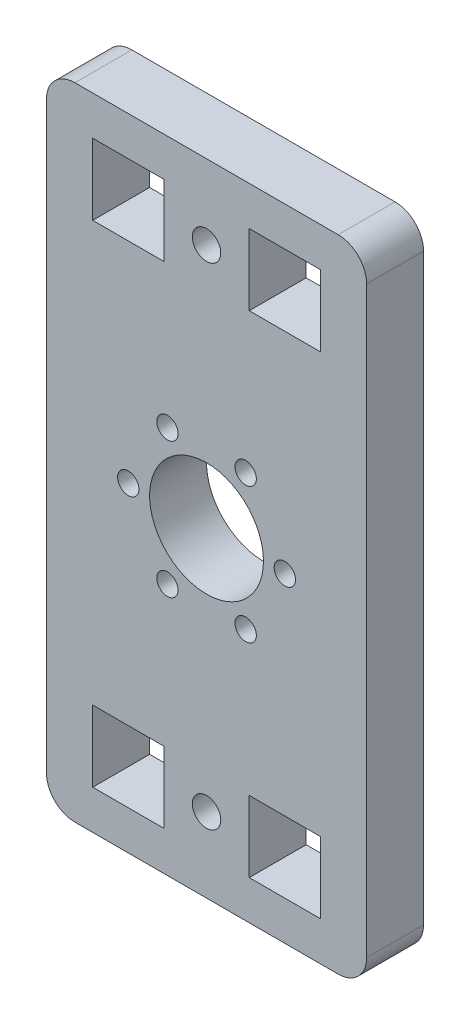
from build123d import *

# Parameters (mm, degrees)
SKETCH1_R           = 8
SKETCH1_R_2         = 1.5
SKETCH1_R_3         = 2
SKETCH1_W           = 10
SKETCH1_H           = 10
BOSS_EXTRUDE2_DEPTH = 8


with BuildPart() as part:
    # Sketch1 → Boss-Extrude2 (new body)
    with BuildSketch(Plane.XY):
        with BuildLine():
            Line((18.5, -45), (-18.5, -45))
            ThreePointArc((-18.5, -45), (-21.328427125, -43.828427125), (-22.5, -41))
            Line((-22.5, -41), (-22.5, 41))
            ThreePointArc((-22.5, 41), (-21.328427125, 43.828427125), (-18.5, 45))
            Line((-18.5, 45), (18.5, 45))
            ThreePointArc((18.5, 45), (21.328427125, 43.828427125), (22.5, 41))
            Line((22.5, 41), (22.5, -41))
            ThreePointArc((22.5, -41), (21.328427125, -43.828427125), (18.5, -45))
        make_face()
        Circle(SKETCH1_R, mode=Mode.SUBTRACT)
        with Locations((-11, 0)):
            Circle(SKETCH1_R_2, mode=Mode.SUBTRACT)
        with Locations((-5.5, 9.526279442)):
            Circle(SKETCH1_R_2, mode=Mode.SUBTRACT)
        with Locations((5.5, 9.526279442)):
            Circle(SKETCH1_R_2, mode=Mode.SUBTRACT)
        with Locations((11, 0)):
            Circle(SKETCH1_R_2, mode=Mode.SUBTRACT)
        with Locations((5.5, -9.526279442)):
            Circle(SKETCH1_R_2, mode=Mode.SUBTRACT)
        with Locations((-5.5, -9.526279442)):
            Circle(SKETCH1_R_2, mode=Mode.SUBTRACT)
        with Locations((0, -34.5)):
            Circle(SKETCH1_R_3, mode=Mode.SUBTRACT)
        with Locations((0, 34.5)):
            Circle(SKETCH1_R_3, mode=Mode.SUBTRACT)
        with Locations((-11, -34.5)):
            Rectangle(SKETCH1_W, SKETCH1_H, mode=Mode.SUBTRACT)
        with Locations((11, -34.5)):
            Rectangle(SKETCH1_W, SKETCH1_H, mode=Mode.SUBTRACT)
        with Locations((11, 34.5)):
            Rectangle(SKETCH1_W, SKETCH1_H, mode=Mode.SUBTRACT)
        with Locations((-11, 34.5)):
            Rectangle(SKETCH1_W, SKETCH1_H, mode=Mode.SUBTRACT)
    extrude(amount=BOSS_EXTRUDE2_DEPTH)


solid = part.part
